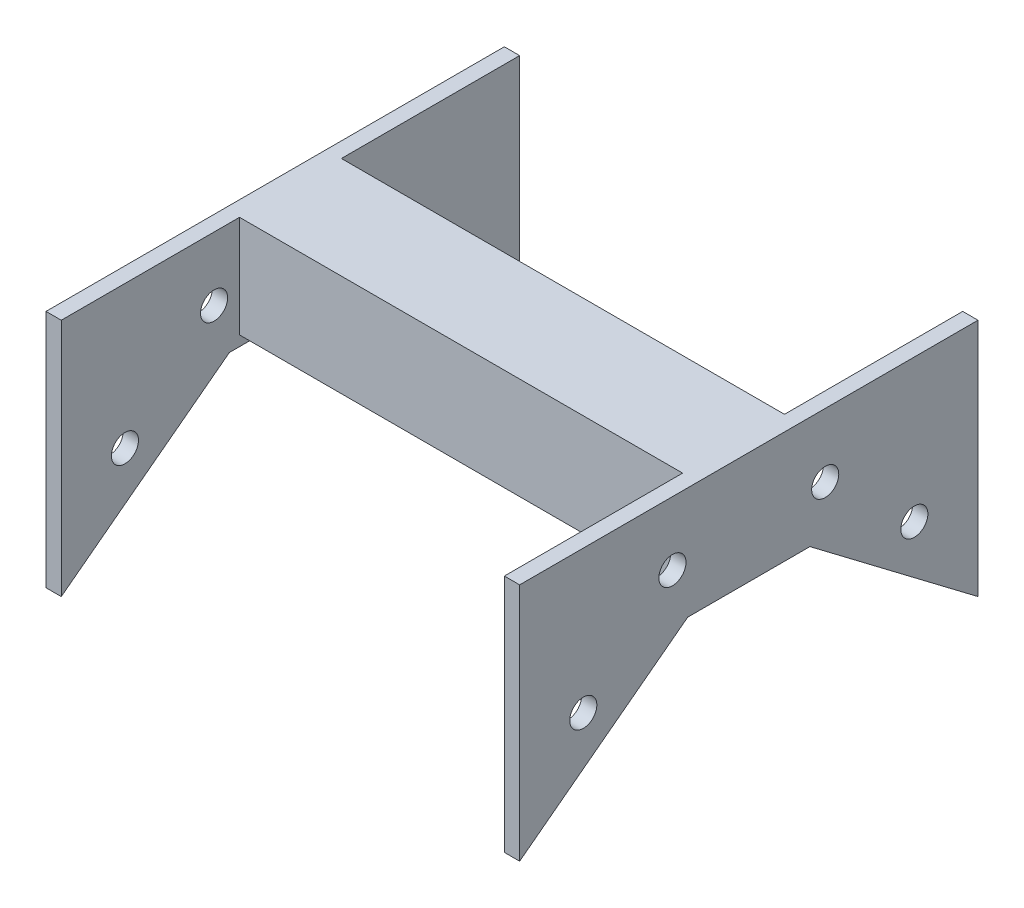
from build123d import *

# Parameters (mm, degrees)
BOSS_EXTRUDE1_DEPTH = 3.81
SKETCH3_W           = 25.4
SKETCH3_H           = 25.4
BOSS_EXTRUDE2_DEPTH = 55.245
SKETCH4_R           = 3.3782
CUT_EXTRUDE1_DEPTH  = 55.245
SCALE1_SCALE        = 1.02


with BuildPart() as part:
    # Sketch2 → Boss-Extrude1 (new body)
    with BuildSketch(Plane(origin=(0, 0, 0), x_dir=(0, 0, -1), z_dir=(1, 0, 0))):
        Polygon((15.24, 0), (-15.24, 0), (-57.15, -31.75), (-57.15, 27.94), (57.15, 27.94), (57.15, -31.75), align=None)
    boss_extrude1 = extrude(amount=BOSS_EXTRUDE1_DEPTH)

    # Sketch3 → Boss-Extrude2 (add)
    with BuildSketch(Plane(origin=(3.81, 0, 0), x_dir=(0, 0, -1), z_dir=(1, 0, 0))):
        with Locations((0, 15.24)):
            Rectangle(SKETCH3_W, SKETCH3_H)
    boss_extrude2 = extrude(amount=BOSS_EXTRUDE2_DEPTH)

    # Sketch4 → Cut-Extrude1 (cut)
    with BuildSketch(Plane.ZY):
        with Locations((19.05, 12.065)):
            Circle(SKETCH4_R)
        with Locations((41.275, -7.62)):
            Circle(SKETCH4_R)
        with Locations((-41.275, -7.62)):
            Circle(SKETCH4_R)
        with Locations((-19.05, 12.065)):
            Circle(SKETCH4_R)
    cut_extrude1 = extrude(amount=-CUT_EXTRUDE1_DEPTH, mode=Mode.SUBTRACT)

    # Mirror1: Boss-Extrude1, Boss-Extrude2, Cut-Extrude1 across plane
    add(boss_extrude1.mirror(Plane(origin=(59.055, 0, 0), x_dir=(0, 0, 1), z_dir=(1, 0, 0))))
    add(boss_extrude2.mirror(Plane(origin=(59.055, 0, 0), x_dir=(0, 0, 1), z_dir=(1, 0, 0))))
    add(cut_extrude1.mirror(Plane(origin=(59.055, 0, 0), x_dir=(0, 0, 1), z_dir=(1, 0, 0))), mode=Mode.SUBTRACT)


with BuildPart() as part_1:
    # Scale1: scaled about (59.055, 12.578988161, 0)
    add(part.part.scale(SCALE1_SCALE).moved(Location((-1.1811, -0.251579763, 0))))


solid = part_1.part
